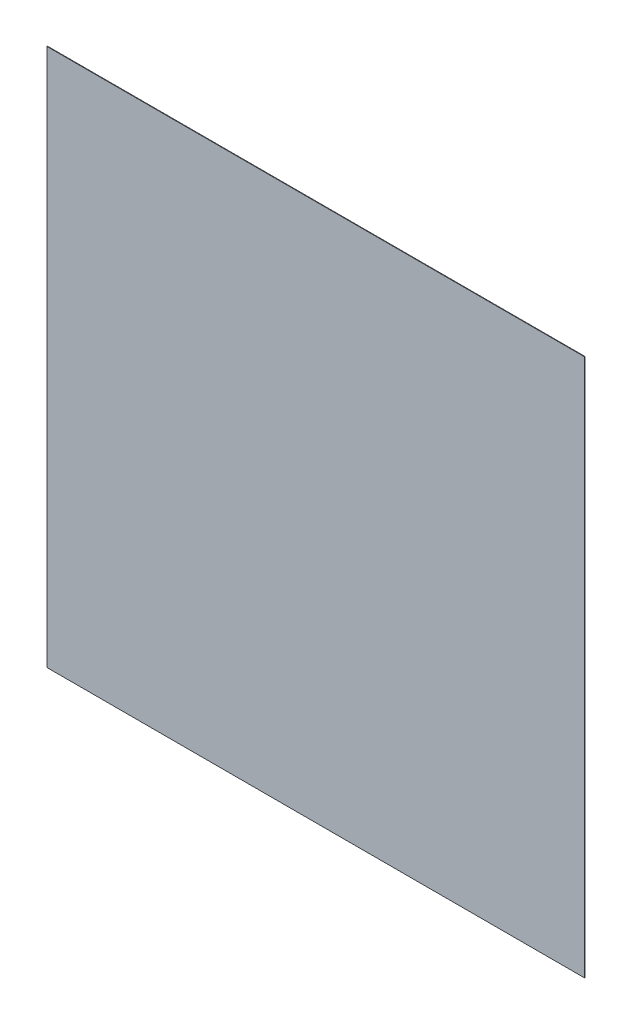
from build123d import *

# Parameters (mm, degrees)
SKETCH1_W           = 1000
SKETCH1_H           = 1000
BOSS_EXTRUDE1_DEPTH = 1


with BuildPart() as part:
    # Sketch1 → Boss-Extrude1 (new body)
    with BuildSketch(Plane.XY):
        with Locations((192.473113411, -348.607574172)):
            Rectangle(SKETCH1_W, SKETCH1_H)
    extrude(amount=BOSS_EXTRUDE1_DEPTH)


solid = part.part
